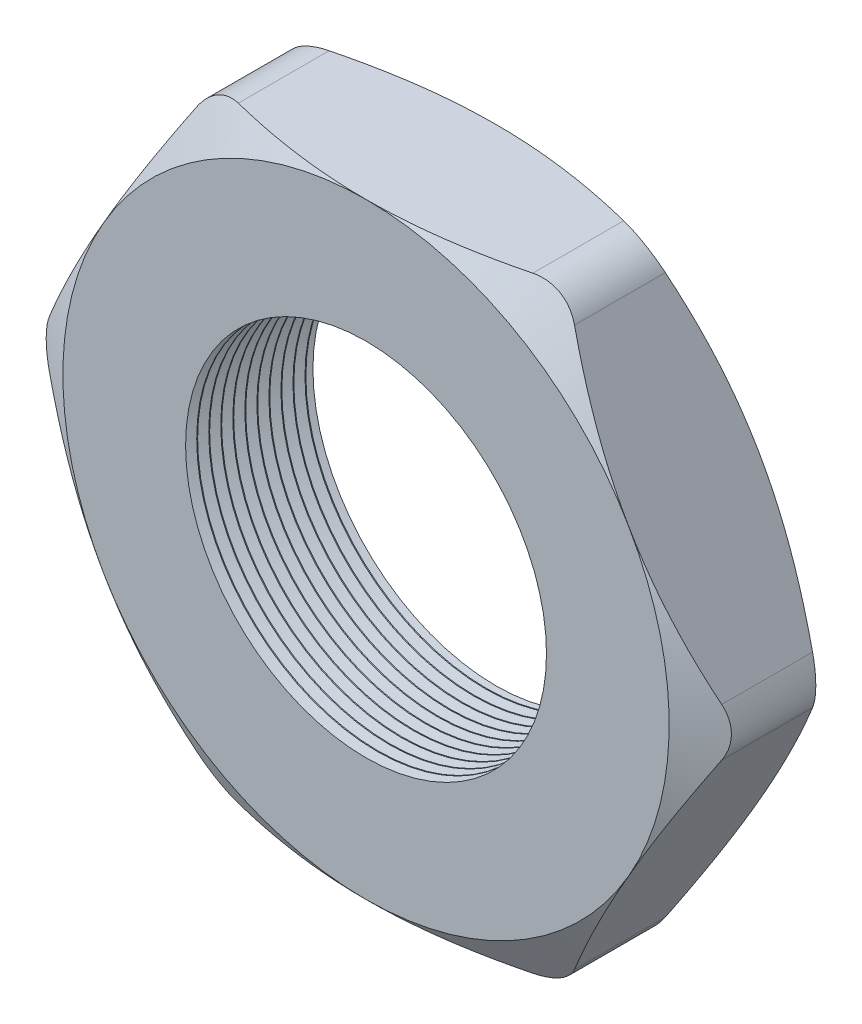
from build123d import *

# Parameters (mm, degrees)
SKETCH1_R          = 9.525
EXTRUDE1_DEPTH     = 6.858
SKETCH2_OUTSIDE_W  = 76.05
SKETCH2_OUTSIDE_H  = 71.098
SKETCH2_OUTSIDE_R  = 16.002
CUT_EXTRUDE1_DEPTH = 7.858
CUT_EXTRUDE1_DRAFT = -60
SKETCH3_OUTSIDE_W  = 76.05
SKETCH3_OUTSIDE_H  = 71.098
SKETCH3_OUTSIDE_R  = 16.002
CUT_EXTRUDE2_DEPTH = 7.858
CUT_EXTRUDE2_DRAFT = -60
FILLET1_R          = 2.54
LPATTERN1_COUNT    = 11
LPATTERN1_PITCH    = 0.635


with BuildPart() as part:
    # Sketch1 → Extrude1 (new body)
    with BuildSketch(Plane.XY):
        Polygon((-18.477518015, 0), (-9.238759008, -16.002), (9.238759008, -16.002), (18.477518015, 0), (9.238759008, 16.002), (-9.238759008, 16.002), align=None)
        Circle(SKETCH1_R, mode=Mode.SUBTRACT)
    extrude(amount=EXTRUDE1_DEPTH)


with BuildPart() as cut_extrude1_tool:
    # Sketch2 outside → Cut-Extrude1 (with draft: the straight prism first)
    with BuildSketch(Plane.XY.offset(6.858)):
        Rectangle(SKETCH2_OUTSIDE_W, SKETCH2_OUTSIDE_H)
        Circle(SKETCH2_OUTSIDE_R, mode=Mode.SUBTRACT)
    extrude(amount=-CUT_EXTRUDE1_DEPTH)
    # Cut-Extrude1: the draft: its side faces are tilted about the plane it starts from
    cut_extrude1_sides = [cut_extrude1_tool.faces().sort_by_distance(p)[0] for p in [
        (0, -35.549, 2.929),
        (38.025, 0, 2.929),
        (0, 35.549, 2.929),
        (-38.025, 0, 2.929),
        (-16.002, 0, 2.929),
    ]]
    draft(cut_extrude1_sides, Plane.XY.offset(6.858), CUT_EXTRUDE1_DRAFT)


with BuildPart() as part_1:
    add(part.part)

    # Cut-Extrude1: cut by cut_extrude1_tool
    add(cut_extrude1_tool.part, mode=Mode.SUBTRACT)


with BuildPart() as cut_extrude2_tool:
    # Sketch3 outside → Cut-Extrude2 (with draft: the straight prism first)
    with BuildSketch(Plane(origin=(0, 0, 0), x_dir=(-1, 0, 0), z_dir=(0, 0, -1))):
        Rectangle(SKETCH3_OUTSIDE_W, SKETCH3_OUTSIDE_H)
        Circle(SKETCH3_OUTSIDE_R, mode=Mode.SUBTRACT)
    extrude(amount=-CUT_EXTRUDE2_DEPTH)
    # Cut-Extrude2: the draft: its side faces are tilted about the plane it starts from
    cut_extrude2_sides = [cut_extrude2_tool.faces().sort_by_distance(p)[0] for p in [
        (0, -35.549, 3.929),
        (-38.025, 0, 3.929),
        (0, 35.549, 3.929),
        (38.025, 0, 3.929),
        (16.002, 0, 3.929),
    ]]
    draft(cut_extrude2_sides, Plane(origin=(0, 0, 0), x_dir=(-1, 0, 0), z_dir=(0, 0, -1)), CUT_EXTRUDE2_DRAFT)


with BuildPart() as part_2:
    add(part_1.part)

    # Cut-Extrude2: cut by cut_extrude2_tool
    add(cut_extrude2_tool.part, mode=Mode.SUBTRACT)

    # Fillet1
    fillet1_edges = [part_2.edges().sort_by_distance(p)[0] for p in [
        (18.477518015, 0, 3.429),
        (9.238759008, -16.002, 3.429),
        (-9.238759008, -16.002, 3.429),
        (-18.477518015, 0, 3.429),
        (-9.238759008, 16.002, 3.429),
        (9.238759008, 16.002, 3.429),
    ]]
    fillet(fillet1_edges, radius=FILLET1_R)

    # Sketch4 → Cut-Revolve1 (revolve, cut)
    with BuildSketch(Plane(origin=(0, 0, 0), x_dir=(1, 0, 0), z_dir=(0, 1, 0)), mode=Mode.PRIVATE) as cut_revolve1_sk:
        Polygon((-9.525, -6.858), (-9.525, -6.271412127), (-10.033, -6.564706063), align=None)
    cut_revolve1 = revolve(cut_revolve1_sk.sketch.rotate(Axis((0, 0, 0), (0, 0, 1)), 180), axis=Axis((0, 0, 0), (0, 0, 1)), mode=Mode.SUBTRACT)  # turned: the seam where the file's is

    # LPattern1: Cut-Revolve1 ×11
    with Locations(*[(0, 0, -i * LPATTERN1_PITCH) for i in range(1, LPATTERN1_COUNT)]):
        add(cut_revolve1, mode=Mode.SUBTRACT)


solid = part_2.part
